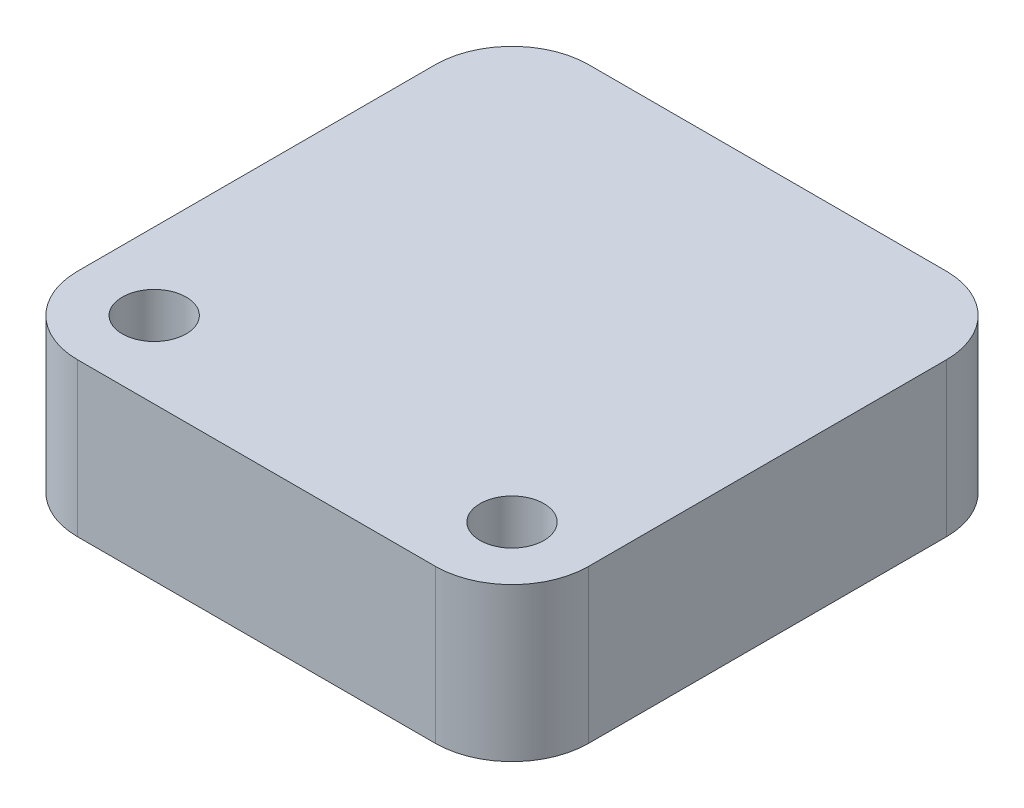
from build123d import *

# Parameters (mm, degrees)
SKETCH1_W               = 20
SKETCH1_H               = 20
BOSS_EXTRUDE1_DEPTH     = 6
FILLET1_R               = 3
SKETCH2_R               = 1.25
CUT_EXTRUDE1_DEPTH      = 1
CUT_EXTRUDE1_DEPTH_BACK = 7


with BuildPart() as part:
    # Sketch1 → Boss-Extrude1 (new body)
    with BuildSketch(Plane(origin=(0, 0, 0), x_dir=(1, 0, 0), z_dir=(0, 1, 0))):
        with Locations((10, 10)):
            Rectangle(SKETCH1_W, SKETCH1_H)
    extrude(amount=BOSS_EXTRUDE1_DEPTH)

    # Fillet1
    fillet1_edges = [part.edges().sort_by_distance(p)[0] for p in [
        (0, 3, -20),
        (20, 3, -20),
        (20, 3, 0),
        (0, 3, 0),
    ]]
    fillet(fillet1_edges, radius=FILLET1_R)

    # Sketch2 → Cut-Extrude1 (cut, two sides)
    with BuildSketch(Plane(origin=(0, 6, 0), x_dir=(1, 0, 0), z_dir=(0, 1, 0))) as cut_extrude1_sk:
        with Locations((3, 3)):
            Circle(SKETCH2_R)
        with Locations((17, 3)):
            Circle(SKETCH2_R)
    extrude(amount=CUT_EXTRUDE1_DEPTH, mode=Mode.SUBTRACT)
    extrude(cut_extrude1_sk.sketch, amount=-CUT_EXTRUDE1_DEPTH_BACK, mode=Mode.SUBTRACT)


solid = part.part
